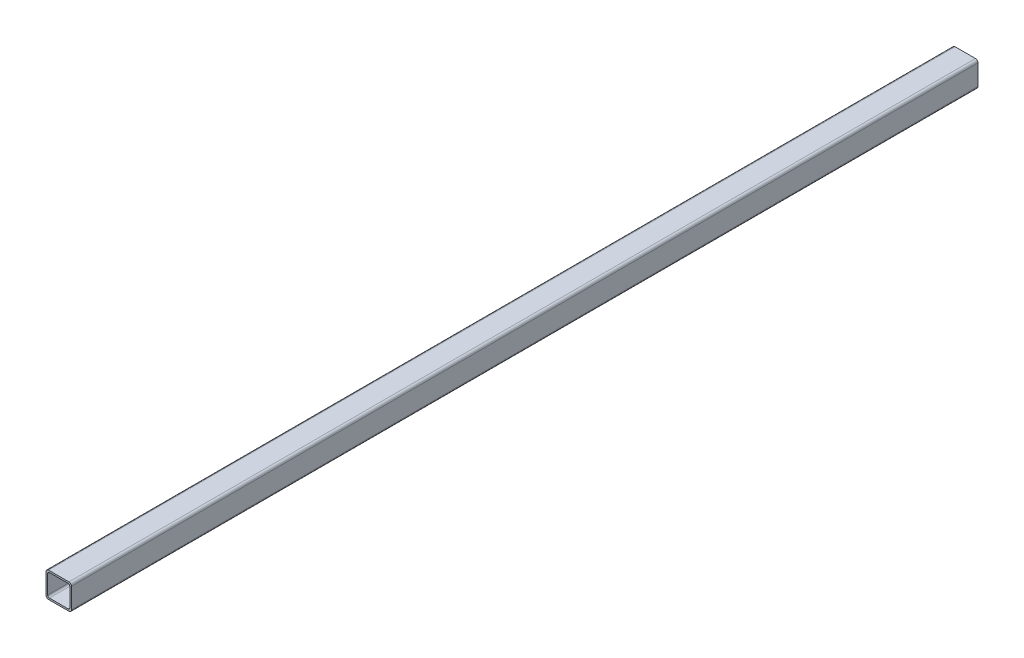
from build123d import *

# Parameters (mm, degrees)
EXTRUDE_1_DEPTH = 534


with BuildPart() as part:
    # Эскиз1 → Бобышка-Вытянуть1 (new body)
    with BuildSketch(Plane.XY.offset(-10)):
        with BuildLine():
            Line((12, 0), (-12, 0))
            ThreePointArc((-12, 0), (-14.121320344, 0.878679656), (-15, 3))
            Line((-15, 3), (-15, 27))
            ThreePointArc((-15, 27), (-14.121320344, 29.121320344), (-12, 30))
            Line((-12, 30), (12, 30))
            ThreePointArc((12, 30), (14.121320344, 29.121320344), (15, 27))
            Line((15, 27), (15, 3))
            ThreePointArc((15, 3), (14.121320344, 0.878679656), (12, 0))
        make_face()
        with BuildLine():
            Line((11, 2), (-11, 2))
            ThreePointArc((-11, 2), (-12.414213562, 2.585786438), (-13, 4))
            Line((-13, 4), (-13, 26))
            ThreePointArc((-13, 26), (-12.414213562, 27.414213562), (-11, 28))
            Line((-11, 28), (11, 28))
            ThreePointArc((11, 28), (12.414213562, 27.414213562), (13, 26))
            Line((13, 26), (13, 4))
            ThreePointArc((13, 4), (12.414213562, 2.585786438), (11, 2))
        make_face(mode=Mode.SUBTRACT)
    extrude(amount=-EXTRUDE_1_DEPTH)

    # Зеркальное отражение1: part across plane


with BuildPart() as part_1:
    add(part.part)
    add(part.part.mirror(Plane(origin=(695.566765073, 158.190477347, -544), x_dir=(1, 0, 0), z_dir=(0, 0, 1))))


solid = part_1.part
